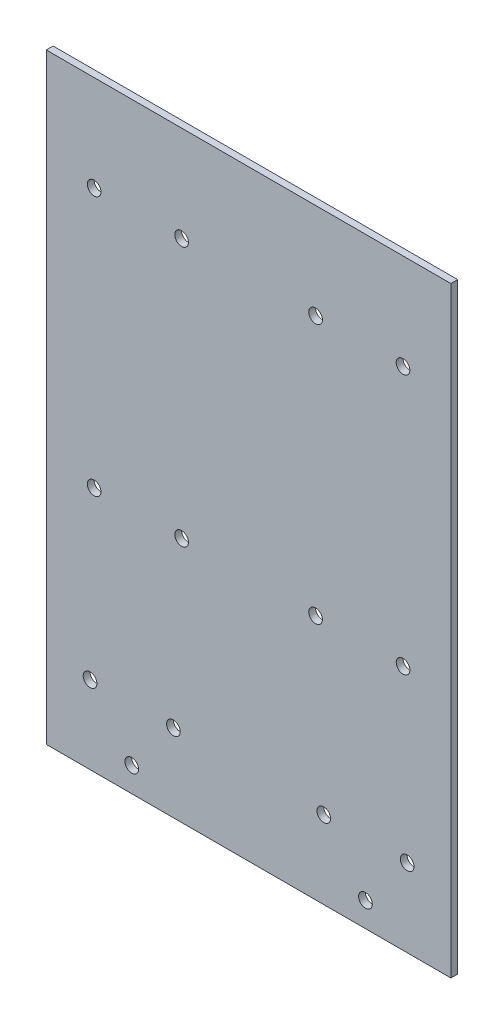
from build123d import *

# Parameters (mm, degrees)
SKETCH_1_W          = 148
SKETCH_1_H          = 220
SKETCH_1_R          = 2.5
EXTRUDE_1_DEPTH     = 2.5
SKETCH_2_R          = 2.5
CUT_EXTRUDE_1_DEPTH = 3


with BuildPart() as part:
    # 草图1 → 凸台-拉伸1 (new body)
    with BuildSketch(Plane.XY):
        Rectangle(SKETCH_1_W, SKETCH_1_H)
        with Locations((-58, -81.5)):
            Circle(SKETCH_1_R, mode=Mode.SUBTRACT)
        with Locations((-27.5, -81.5)):
            Circle(SKETCH_1_R, mode=Mode.SUBTRACT)
        with Locations((-42.75, -101)):
            Circle(SKETCH_1_R, mode=Mode.SUBTRACT)
        with Locations((42.75, -101)):
            Circle(SKETCH_1_R, mode=Mode.SUBTRACT)
        with Locations((58, -81.5)):
            Circle(SKETCH_1_R, mode=Mode.SUBTRACT)
        with Locations((27.5, -81.5)):
            Circle(SKETCH_1_R, mode=Mode.SUBTRACT)
    extrude(amount=EXTRUDE_1_DEPTH)

    # 草图2 → 切除-拉伸1 (cut)
    with BuildSketch(Plane.XY.offset(2.5)):
        with Locations((-56.5, -20)):
            Circle(SKETCH_2_R)
        with Locations((-24.5, -20)):
            Circle(SKETCH_2_R)
        with Locations((-56.5, 75)):
            Circle(SKETCH_2_R)
        with Locations((-24.5, 75)):
            Circle(SKETCH_2_R)
        with Locations((-56.5, 170)):
            Circle(SKETCH_2_R)
        with Locations((-24.5, 170)):
            Circle(SKETCH_2_R)
        with Locations((24.5, 170)):
            Circle(SKETCH_2_R)
        with Locations((56.5, 170)):
            Circle(SKETCH_2_R)
        with Locations((24.5, 75)):
            Circle(SKETCH_2_R)
        with Locations((56.5, 75)):
            Circle(SKETCH_2_R)
        with Locations((24.5, -20)):
            Circle(SKETCH_2_R)
        with Locations((56.5, -20)):
            Circle(SKETCH_2_R)
    extrude(amount=-CUT_EXTRUDE_1_DEPTH, mode=Mode.SUBTRACT)


solid = part.part
